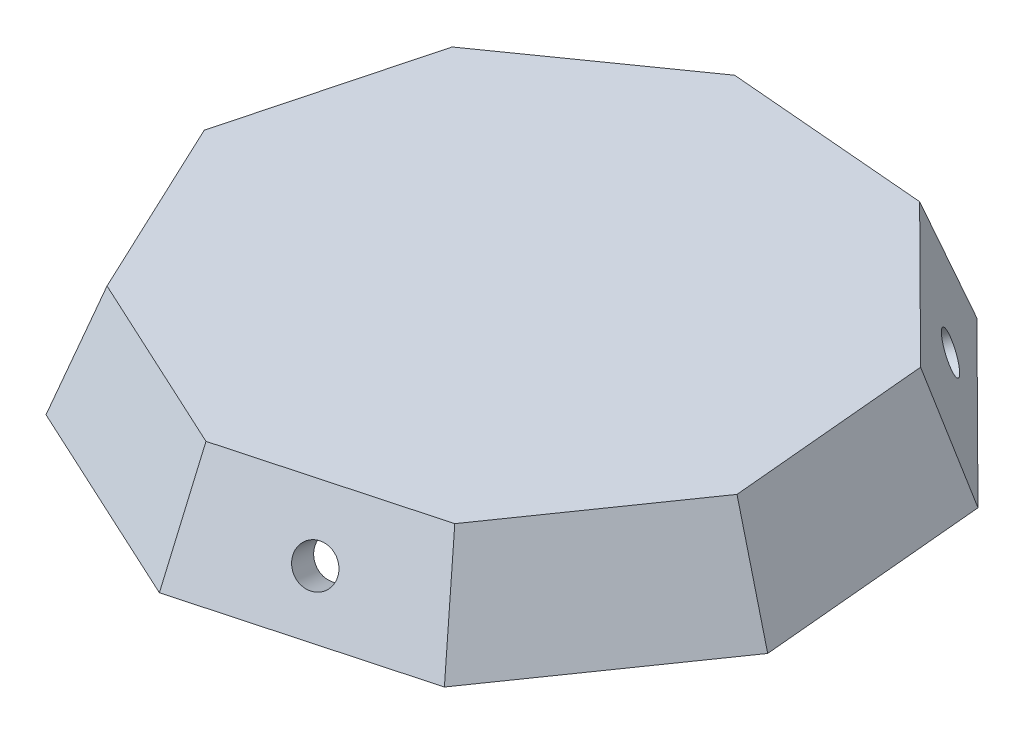
from build123d import *

# Parameters (mm, degrees)
BOSS_EXTRUDE1_DEPTH = 10
DRAFT1_ANGLE        = 20
SHELL1_T            = -3
SKETCH3_R           = 1.7
CUT_EXTRUDE1_DEPTH  = 3
CIRPATTERN1_COUNT   = 3


with BuildPart() as part:
    # Sketch2 → Boss-Extrude1 (new body)
    with BuildSketch(Plane(origin=(0, 0, 0), x_dir=(1, 0, 0), z_dir=(0, 1, 0))):
        Polygon((25.720557456, -6.800689768), (24.074489233, 11.323225041), (11.16369994, 24.148877009), (-6.970708626, 25.67500104), (-21.843445154, 15.187506739), (-26.495390933, -2.406390756), (-18.74984883, -18.874311272), (-2.231044079, -26.510731779), (15.331690993, -21.742486253), align=None)
    extrude(amount=BOSS_EXTRUDE1_DEPTH)

    # Draft1
    draft1_faces = [part.faces().sort_by_distance(p)[0] for p in [
        (-24.169418044, 5, -6.390557991),
        (-14.40707689, 5, -20.431253889),
        (2.096495657, 5, -24.911939024),
        (17.619094586, 5, -17.736051025),
        (24.897523344, 5, -2.261267636),
        (20.526124224, 5, 14.27158801),
        (-10.490446454, 5, 22.692521526),
        (-22.622619881, 5, 10.640351014),
        (6.550323457, 5, 24.126609016),
    ]]
    draft(draft1_faces, Plane.ZX.offset(10), DRAFT1_ANGLE)

    # Shell1
    shell1_openings = [part.faces().sort_by_distance(p)[0] for p in [
        (0, 0, 0),
    ]]
    offset(amount=SHELL1_T, openings=shell1_openings, kind=Kind.INTERSECTION)

    # Sketch3 → Cut-Extrude1 (cut)
    with BuildSketch(Plane(origin=(6.626174522, 9.204622905, 24.40598896), x_dir=(0.969216093, -0.086883963, -0.23037218), z_dir=(0.246211625, 0.342020143, 0.906863858))):
        with Locations((0.443378447, -4.774813723)):
            Circle(SKETCH3_R)
    cut_extrude1 = extrude(amount=-CUT_EXTRUDE1_DEPTH, mode=Mode.SUBTRACT)

    # CirPattern1: Cut-Extrude1 ×3 about axis
    cirpattern1_axis = Axis((0, 10, 0), (0, 1, 0))
    for i in range(1, CIRPATTERN1_COUNT):
        add(cut_extrude1.rotate(cirpattern1_axis, i * 360 / CIRPATTERN1_COUNT), mode=Mode.SUBTRACT)


solid = part.part
